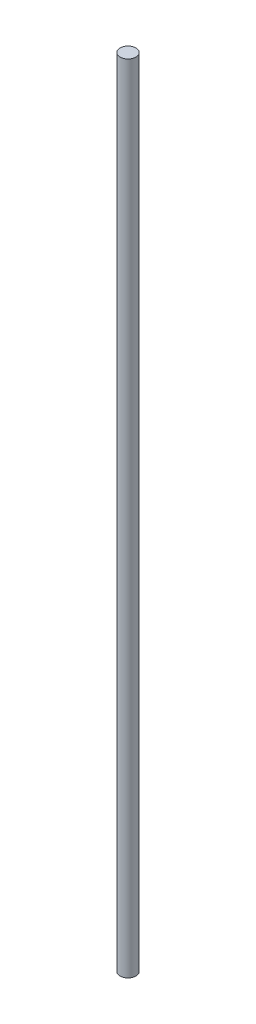
from build123d import *

# Parameters (mm, degrees)
SKETCH_1_R      = 4
EXTRUDE_1_DEPTH = 400


with BuildPart() as part:
    # 草图1 → 凸台-拉伸1 (new body)
    with BuildSketch(Plane(origin=(0, 0, 0), x_dir=(1, 0, 0), z_dir=(0, 1, 0))):
        Circle(SKETCH_1_R)
    extrude(amount=EXTRUDE_1_DEPTH)


solid = part.part
